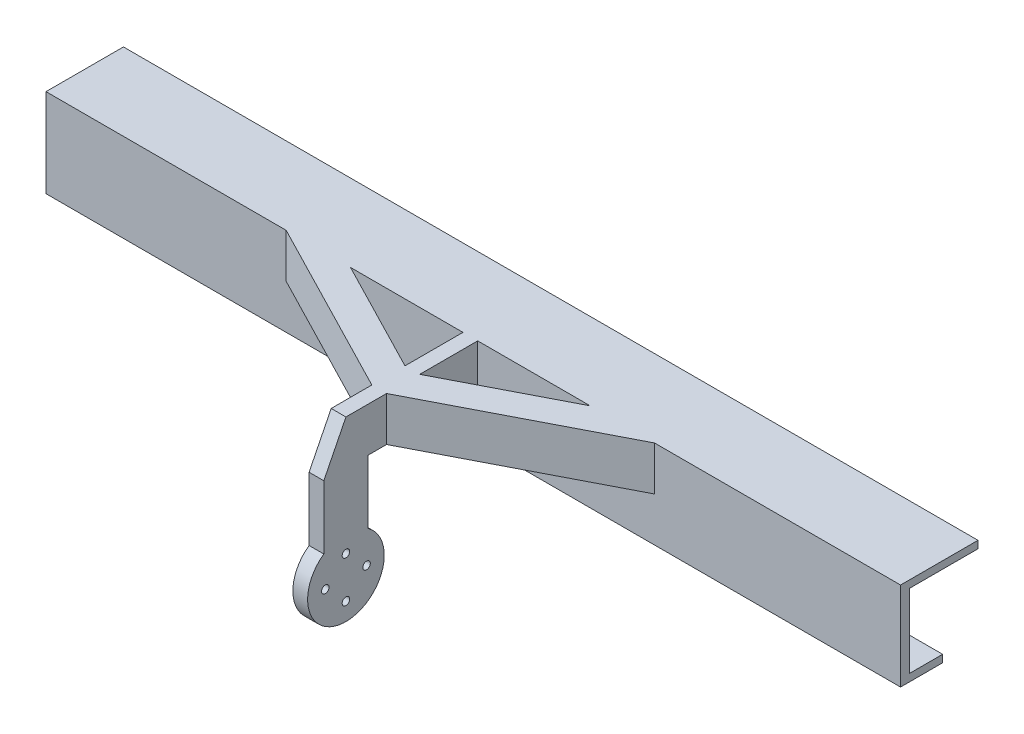
from build123d import *

# Parameters (mm, degrees)
SKETCH2_W                = 290
SKETCH2_H                = 30
SKETCH2_W_2              = 280
SKETCH2_H_2              = 25
BOSS_EXTRUDE1_DEPTH      = 23.28
SKETCH3_W                = 290
SKETCH3_H                = 30
BOSS_EXTRUDE2_DEPTH      = 3
SKETCH4_W                = 23.28
SKETCH4_H                = 25
CUT_EXTRUDE1_DEPTH       = 1
CUT_EXTRUDE1_DEPTH_BACK  = 291
BOSS_EXTRUDE3_DEPTH      = 2
BOSS_EXTRUDE3_DEPTH_BACK = 3
SKETCH6_R                = 10
CUT_EXTRUDE2_DEPTH       = 2
SKETCH7_R                = 1.275
CUT_EXTRUDE3_DEPTH       = 10
SKETCH8_W                = 290
SKETCH8_H                = 2.5
CUT_EXTRUDE4_DEPTH       = 12
BOSS_EXTRUDE4_DEPTH      = 15


with BuildPart() as part:
    # Sketch2 → Boss-Extrude1 (new body)
    with BuildSketch(Plane.XY.offset(1.715456747)):
        Rectangle(SKETCH2_W, SKETCH2_H)
        Rectangle(SKETCH2_W_2, SKETCH2_H_2, mode=Mode.SUBTRACT)
    extrude(amount=BOSS_EXTRUDE1_DEPTH)

    # Sketch3 → Boss-Extrude2 (add)
    with BuildSketch(Plane.XY.offset(24.995456747)):
        Rectangle(SKETCH3_W, SKETCH3_H)
    extrude(amount=BOSS_EXTRUDE2_DEPTH)

    # Sketch4 → Cut-Extrude1 (cut, two sides)
    with BuildSketch(Plane(origin=(145, 0, 0), x_dir=(0, 0, -1), z_dir=(1, 0, 0))) as cut_extrude1_sk:
        with Locations((-13.355456747, 0)):
            Rectangle(SKETCH4_W, SKETCH4_H)
    extrude(amount=CUT_EXTRUDE1_DEPTH, mode=Mode.SUBTRACT)
    extrude(cut_extrude1_sk.sketch, amount=-CUT_EXTRUDE1_DEPTH_BACK, mode=Mode.SUBTRACT)

    # Sketch5 → Boss-Extrude3 (add, two sides)
    with BuildSketch(Plane(origin=(-0.5, 0, 0), x_dir=(0, 0, -1), z_dir=(1, 0, 0))) as boss_extrude3_sk:
        with BuildLine():
            Line((-27.995456747, 0), (-27.995456747, 15))
            Line((-27.995456747, 15), (-72.715456747, 15))
            Line((-72.715456747, 15), (-80.215456747, 0))
            Line((-80.215456747, 0), (-80.215456747, -21.531619709))
            ThreePointArc((-80.215456747, -21.531619709), (-72.715456747, -45.15), (-65.215456747, -21.531619709))
            Line((-65.215456747, -21.531619709), (-65.215456747, 0))
            Line((-65.215456747, 0), (-27.995456747, 0))
        make_face()
    extrude(amount=BOSS_EXTRUDE3_DEPTH)
    extrude(boss_extrude3_sk.sketch, amount=-BOSS_EXTRUDE3_DEPTH_BACK)

    # Sketch6 → Cut-Extrude2 (cut)
    with BuildSketch(Plane(origin=(-3.5, 0, 0), x_dir=(0, 0, -1), z_dir=(1, 0, 0))):
        with Locations((-72.715456747, -32.15)):
            Circle(SKETCH6_R)
    extrude(amount=CUT_EXTRUDE2_DEPTH, mode=Mode.SUBTRACT)

    # Sketch7 → Cut-Extrude3 (cut)
    with BuildSketch(Plane.ZY.offset(3.5)):
        with Locations((72.715456747, -25.15)):
            Circle(SKETCH7_R)
        with Locations((79.715456747, -32.15)):
            Circle(SKETCH7_R)
        with Locations((72.715456747, -39.15)):
            Circle(SKETCH7_R)
        with Locations((65.715456747, -32.15)):
            Circle(SKETCH7_R)
    extrude(amount=-CUT_EXTRUDE3_DEPTH, mode=Mode.SUBTRACT)

    # Sketch8 → Cut-Extrude4 (cut)
    with BuildSketch(Plane(origin=(0, 0, 1.715456747), x_dir=(-1, 0, 0), z_dir=(0, 0, -1))):
        with Locations((0, -13.75)):
            Rectangle(SKETCH8_W, SKETCH8_H)
    extrude(amount=-CUT_EXTRUDE4_DEPTH, mode=Mode.SUBTRACT)

    # Sketch9 → Boss-Extrude4 (add)
    with BuildSketch(Plane(origin=(0, 15, 0), x_dir=(1, 0, 0), z_dir=(0, 1, 0))):
        Polygon((-3.5, -58.92224084), (-63.5, -27.995456747), (-41.673741056, -27.995456747), (-3.5, -47.671974209), align=None)
        Polygon((61.5, -27.995456747), (39.673741056, -27.995456747), (1.5, -47.671974209), (1.5, -58.92224084), align=None)
    extrude(amount=-BOSS_EXTRUDE4_DEPTH)


solid = part.part
